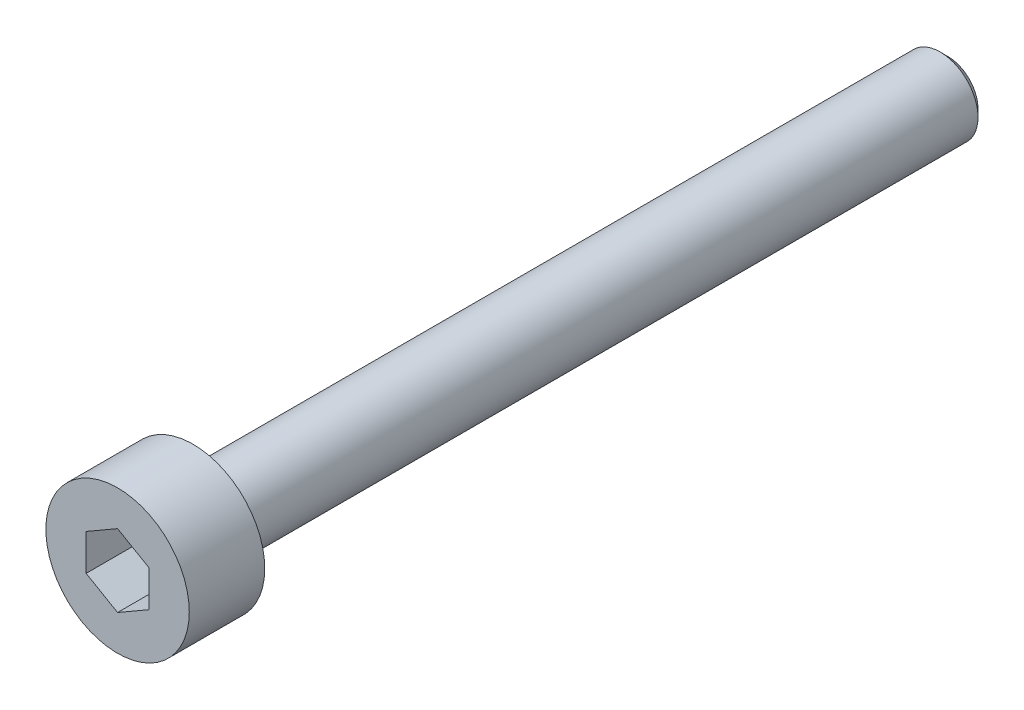
from build123d import *

# Parameters (mm, degrees)
SKETCH1_R           = 2.85
BOSS_EXTRUDE1_DEPTH = 3
SKETCH2_R           = 1.5
BOSS_EXTRUDE2_DEPTH = 30
CHAMFER1_SIZE       = 0.3
CUT_EXTRUDE1_DEPTH  = 2


with BuildPart() as part:
    # Sketch1 → Boss-Extrude1 (new body)
    with BuildSketch(Plane.XY):
        Circle(SKETCH1_R)
    extrude(amount=BOSS_EXTRUDE1_DEPTH)

    # Sketch2 → Boss-Extrude2 (add)
    with BuildSketch(Plane(origin=(0, 0, 0), x_dir=(-1, 0, 0), z_dir=(0, 0, -1))):
        Circle(SKETCH2_R)
    extrude(amount=BOSS_EXTRUDE2_DEPTH)

    # Chamfer1
    chamfer1_edges = [part.edges().sort_by_distance(p)[0] for p in [
        (1.5, 0, -30),
    ]]
    chamfer(chamfer1_edges, length=CHAMFER1_SIZE)

    # Sketch3 → Cut-Extrude1 (cut)
    with BuildSketch(Plane.XY.offset(3)):
        Polygon((0, 1.443375673), (-1.25, 0.721687836), (-1.25, -0.721687836), (0, -1.443375673), (1.25, -0.721687836), (1.25, 0.721687836), align=None)
    extrude(amount=-CUT_EXTRUDE1_DEPTH, mode=Mode.SUBTRACT)


solid = part.part
